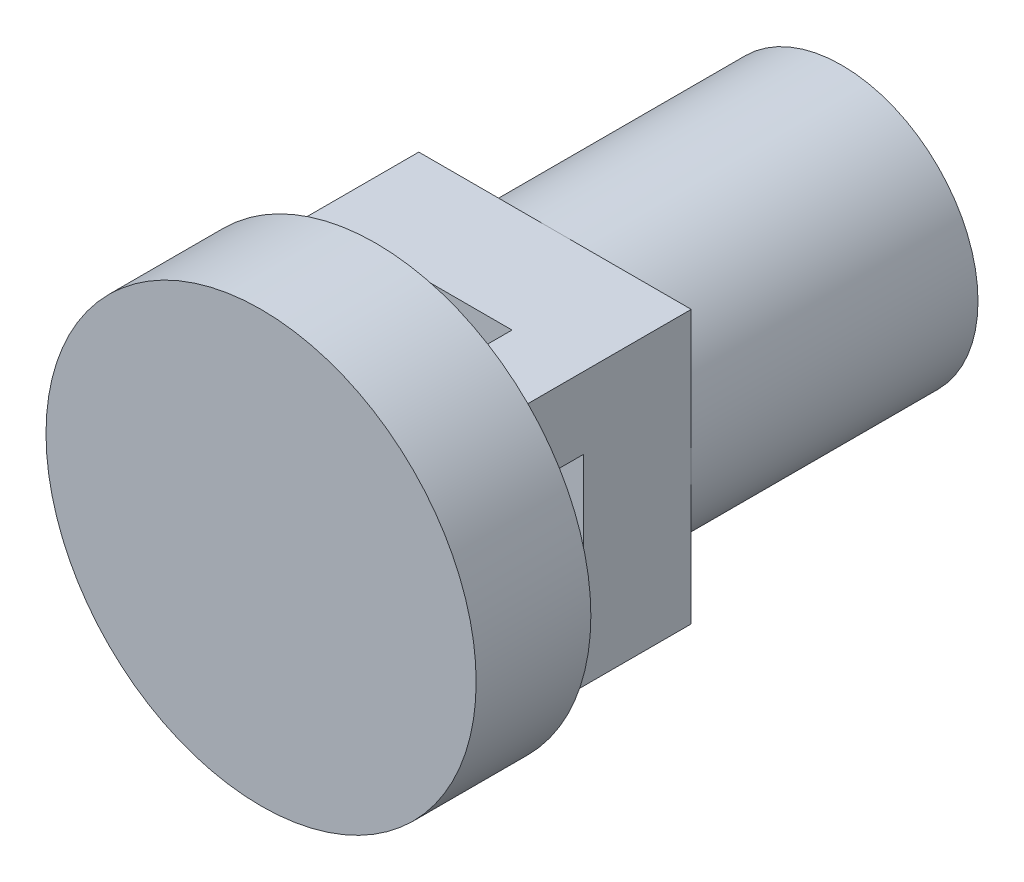
from build123d import *

# Parameters (mm, degrees)
SKETCH_3_R          = 3.00000508
EXTRUDE_1_DEPTH     = 1.6
SKETCH_4_W          = 1
SKETCH_4_H          = 1
EXTRUDE_2_DEPTH     = 1
SKETCH_5_W          = 3.8001016
SKETCH_5_H          = 3.8001016
EXTRUDE_3_DEPTH     = 1.5
SKETCH_6_R          = 1.9000508
EXTRUDE_4_DEPTH     = 4
SKETCH_7_R          = 1.615152196
CUT_EXTRUDE_1_DEPTH = 4
SKETCH_8_R          = 0.601590178
EXTRUDE_5_DEPTH     = 3
SKETCH_9_R          = 0.306574413
CUT_EXTRUDE_2_DEPTH = 3
SKETCH_10_W         = 0.228686602
SKETCH_10_H         = 1.655690995
CUT_EXTRUDE_3_DEPTH = 3


with BuildPart() as part:
    # 草图3 → 凸台-拉伸1 (new body)
    with BuildSketch(Plane.XY):
        with Locations((3.00000508, 3.00000508)):
            Circle(SKETCH_3_R)
    extrude(amount=EXTRUDE_1_DEPTH)

    # 草图4 → 凸台-拉伸2 (add)
    with BuildSketch(Plane(origin=(0, 0, 0), x_dir=(-1, 0, 0), z_dir=(0, 0, -1))):
        with Locations((-1.59995428, 1.59995428)):
            Rectangle(SKETCH_4_W, SKETCH_4_H)
        with Locations((-1.59995428, 4.40005588)):
            Rectangle(SKETCH_4_W, SKETCH_4_H)
        with Locations((-4.40005588, 4.40005588)):
            Rectangle(SKETCH_4_W, SKETCH_4_H)
        with Locations((-4.40005588, 1.59995428)):
            Rectangle(SKETCH_4_W, SKETCH_4_H)
    extrude(amount=EXTRUDE_2_DEPTH)

    # 草图5 → 凸台-拉伸3 (add)
    with BuildSketch(Plane(origin=(0, 0, -1), x_dir=(-1, 0, 0), z_dir=(0, 0, -1))):
        with Locations((-3.00000508, 3.00000508)):
            Rectangle(SKETCH_5_W, SKETCH_5_H)
    extrude(amount=EXTRUDE_3_DEPTH)

    # 草图6 → 凸台-拉伸4 (add)
    with BuildSketch(Plane(origin=(0, 0, -2.5), x_dir=(-1, 0, 0), z_dir=(0, 0, -1))):
        with Locations((-3.00000508, 3.00000508)):
            Circle(SKETCH_6_R)
    extrude(amount=EXTRUDE_4_DEPTH)

    # 草图7 → 切除-拉伸1 (cut)
    with BuildSketch(Plane(origin=(0, 0, -6.5), x_dir=(-1, 0, 0), z_dir=(0, 0, -1))):
        with Locations((-3.00000508, 3.00000508)):
            Circle(SKETCH_7_R)
    extrude(amount=-CUT_EXTRUDE_1_DEPTH, mode=Mode.SUBTRACT)

    # 草图8 → 凸台-拉伸5 (add)
    with BuildSketch(Plane(origin=(0, 0, -2.5), x_dir=(-1, 0, 0), z_dir=(0, 0, -1))):
        with Locations((-3.00000508, 3.00000508)):
            Circle(SKETCH_8_R)
    extrude(amount=EXTRUDE_5_DEPTH)

    # 草图9 → 切除-拉伸2 (cut)
    with BuildSketch(Plane(origin=(0, 0, -5.5), x_dir=(-1, 0, 0), z_dir=(0, 0, -1))):
        with Locations((-3.00000508, 3.00000508)):
            Circle(SKETCH_9_R)
    extrude(amount=-CUT_EXTRUDE_2_DEPTH, mode=Mode.SUBTRACT)

    # 草图10 → 切除-拉伸3 (cut)
    with BuildSketch(Plane(origin=(0, 0, -5.5), x_dir=(-1, 0, 0), z_dir=(0, 0, -1))):
        with Locations((-2.999022369, 2.996212045)):
            Rectangle(SKETCH_10_W, SKETCH_10_H)
    extrude(amount=-CUT_EXTRUDE_3_DEPTH, mode=Mode.SUBTRACT)


solid = part.part
